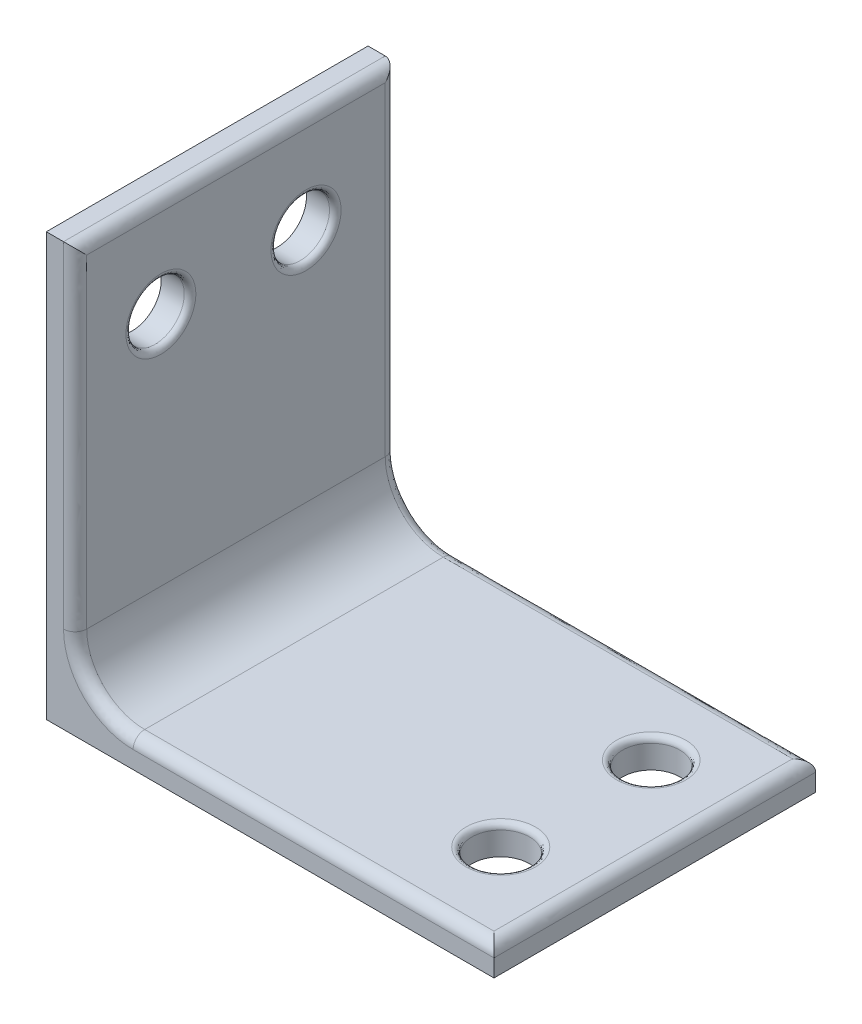
from build123d import *

# Parameters (mm, degrees)
SKETCH1_W           = 77.202171331
SKETCH1_H           = 55.481682761
BOSS_EXTRUDE1_DEPTH = 5
SKETCH2_W           = 4.968888078
SKETCH2_H           = 55.481682761
BOSS_EXTRUDE2_DEPTH = 67.858
SKETCH3_R           = 4.957767387
SKETCH3_R_2         = 4.980451749
CUT_EXTRUDE1_DEPTH  = 67.858
SKETCH4_R           = 5.025637378
SKETCH4_R_2         = 5.040484197
CUT_EXTRUDE2_DEPTH  = 67.858
FILLET1_R           = 10
FILLET2_R           = 2
FILLET3_R           = 1


with BuildPart() as part:
    # Sketch1 → Boss-Extrude1 (new body)
    with BuildSketch(Plane(origin=(0, 0, 0), x_dir=(1, 0, 0), z_dir=(0, 1, 0))):
        with Locations((38.601085666, 27.740841381)):
            Rectangle(SKETCH1_W, SKETCH1_H)
    extrude(amount=BOSS_EXTRUDE1_DEPTH)

    # Sketch2 → Boss-Extrude2 (add)
    with BuildSketch(Plane(origin=(0, 5, 0), x_dir=(1, 0, 0), z_dir=(0, 1, 0))):
        with Locations((2.484444039, 27.740841381)):
            Rectangle(SKETCH2_W, SKETCH2_H)
    extrude(amount=BOSS_EXTRUDE2_DEPTH)

    # Sketch3 → Cut-Extrude1 (cut)
    with BuildSketch(Plane(origin=(0, 5, 0), x_dir=(1, 0, 0), z_dir=(0, 1, 0))):
        with Locations((63.211940842, 41.114585833)):
            Circle(SKETCH3_R)
        with Locations((63.211940842, 15.158442754)):
            Circle(SKETCH3_R_2)
    extrude(amount=-CUT_EXTRUDE1_DEPTH, mode=Mode.SUBTRACT)

    # Sketch4 → Cut-Extrude2 (cut)
    with BuildSketch(Plane(origin=(4.968888078, 0, 0), x_dir=(0, 0, -1), z_dir=(1, 0, 0))):
        with Locations((14.790160446, 55.661727657)):
            Circle(SKETCH4_R)
        with Locations((39.821700462, 55.661727657)):
            Circle(SKETCH4_R_2)
    extrude(amount=-CUT_EXTRUDE2_DEPTH, mode=Mode.SUBTRACT)

    # Fillet1
    fillet1_edges = [part.edges().sort_by_distance(p)[0] for p in [
        (4.968888078, 5, -27.74084138),
    ]]
    fillet(fillet1_edges, radius=FILLET1_R)

    # Fillet2
    fillet2_edges = [part.edges().sort_by_distance(p)[0] for p in [
        (4.968888078, 72.858, -27.74084138),
        (4.968888078, 43.929, -55.481682761),
        (7.897820266, 7.928932188, -55.481682761),
        (46.085529705, 5, -55.481682761),
        (77.202171331, 5, -27.74084138),
        (46.085529705, 5, 0),
        (7.897820266, 7.928932188, 0),
        (4.968888078, 43.929, 0),
    ]]
    fillet(fillet2_edges, radius=FILLET2_R)

    # Fillet3
    fillet3_edges = [part.edges().sort_by_distance(p)[0] for p in [
        (58.254173454, 5, -41.114585833),
        (58.231489093, 5, -15.158442754),
        (4.968888078, 55.661727657, -9.764523068),
        (4.968888078, 55.661727657, -34.781216265),
    ]]
    fillet(fillet3_edges, radius=FILLET3_R)


solid = part.part
